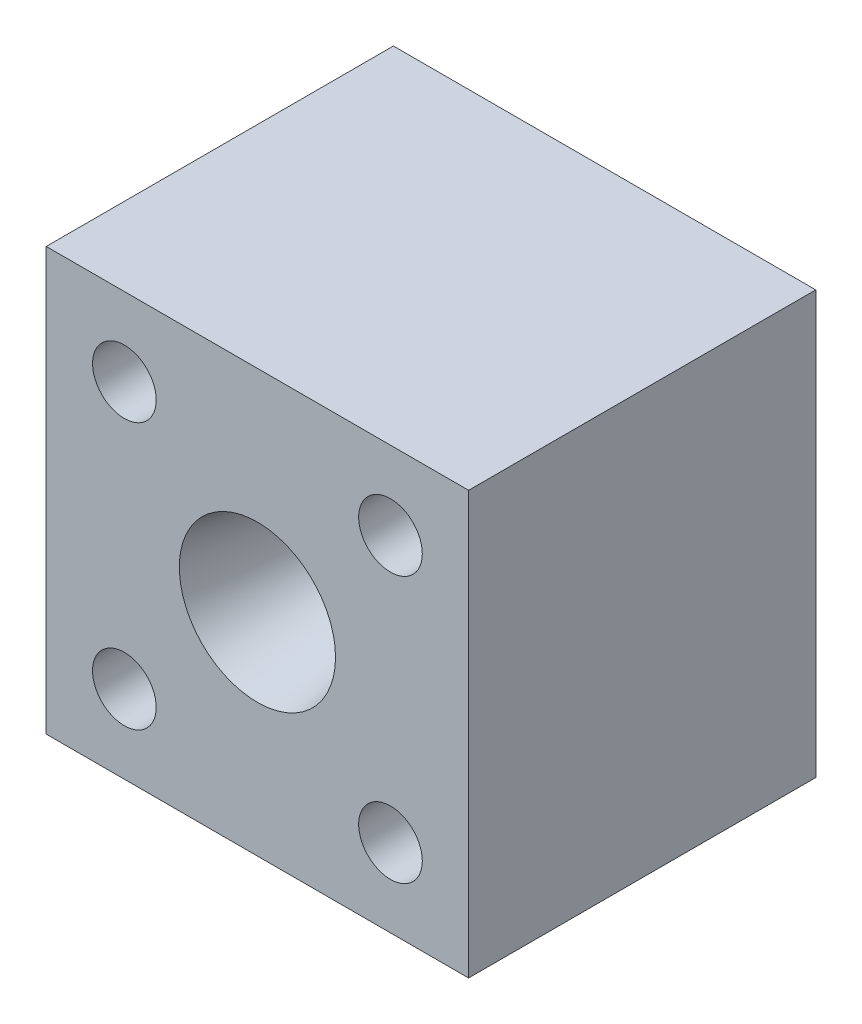
from build123d import *

# Parameters (mm, degrees)
SKETCH1_W               = 46.355
SKETCH1_H               = 46.355
BOSS_EXTRUDE1_DEPTH     = 63.5
SKETCH2_R               = 1.27
CUT_EXTRUDE1_DEPTH      = 64.5
SKETCH4_R               = 3.4925
CUT_EXTRUDE3_DEPTH      = 64.5
MIRROR2_COPY_1_SKETCH_R = 3.4925
MIRROR2_COPY_1_DEPTH    = 64.5
SKETCH6_W               = 50.639915967
SKETCH6_H               = 51.332427637
CUT_EXTRUDE4_DEPTH      = 25.4


with BuildPart() as part:
    # Sketch1 → Boss-Extrude1 (new body)
    with BuildSketch(Plane.XY):
        Rectangle(SKETCH1_W, SKETCH1_H)
    extrude(amount=BOSS_EXTRUDE1_DEPTH)

    # Sketch2 → Cut-Extrude1 (cut, through all)
    with BuildSketch(Plane.XY.offset(63.5)):
        Circle(SKETCH2_R)
    extrude(amount=-CUT_EXTRUDE1_DEPTH, mode=Mode.SUBTRACT)

    # Sketch4 → Cut-Extrude3 (cut, through all)
    with BuildSketch(Plane.XY.offset(63.5)):
        with Locations((14.601896453, 14.601896453)):
            Circle(SKETCH4_R)
    cut_extrude3 = extrude(amount=-CUT_EXTRUDE3_DEPTH, mode=Mode.SUBTRACT)

    # Mirror1: Cut-Extrude3 across plane
    add(cut_extrude3.mirror(Plane.ZX), mode=Mode.SUBTRACT)

    # Mirror2: Cut-Extrude3 across plane
    add(cut_extrude3.mirror(Plane(origin=(0, 0, 0), x_dir=(0, 0, 1), z_dir=(1, 0, 0))), mode=Mode.SUBTRACT)

    # Mirror2 copy 1 sketch → Mirror2 copy 1 (cut, through all)
    with BuildSketch(Plane(origin=(0, 0, 63.5), x_dir=(-1, 0, 0), z_dir=(0, 0, 1))):
        with Locations((14.601896453, 14.601896453)):
            Circle(MIRROR2_COPY_1_SKETCH_R)
    extrude(amount=-MIRROR2_COPY_1_DEPTH, mode=Mode.SUBTRACT)

    # Sketch5 → Cut-Revolve1 (revolve, cut)
    with BuildSketch(Plane(origin=(0, 0, 0), x_dir=(0, 0, -1), z_dir=(1, 0, 0))):
        Polygon((-63.5, 9.713622118), (-44.057941111, 9.713622118), (0, 1.27), (0, 0), (-63.5, 0), align=None)
    revolve(axis=Axis((0, 0, 0), (0, 0, 1)), mode=Mode.SUBTRACT)

    # Sketch6 → Cut-Extrude4 (cut)
    with BuildSketch(Plane.XY.offset(63.5)):
        with Locations((0.281332866, -0.281332866)):
            Rectangle(SKETCH6_W, SKETCH6_H)
    extrude(amount=-CUT_EXTRUDE4_DEPTH, mode=Mode.SUBTRACT)


solid = part.part
